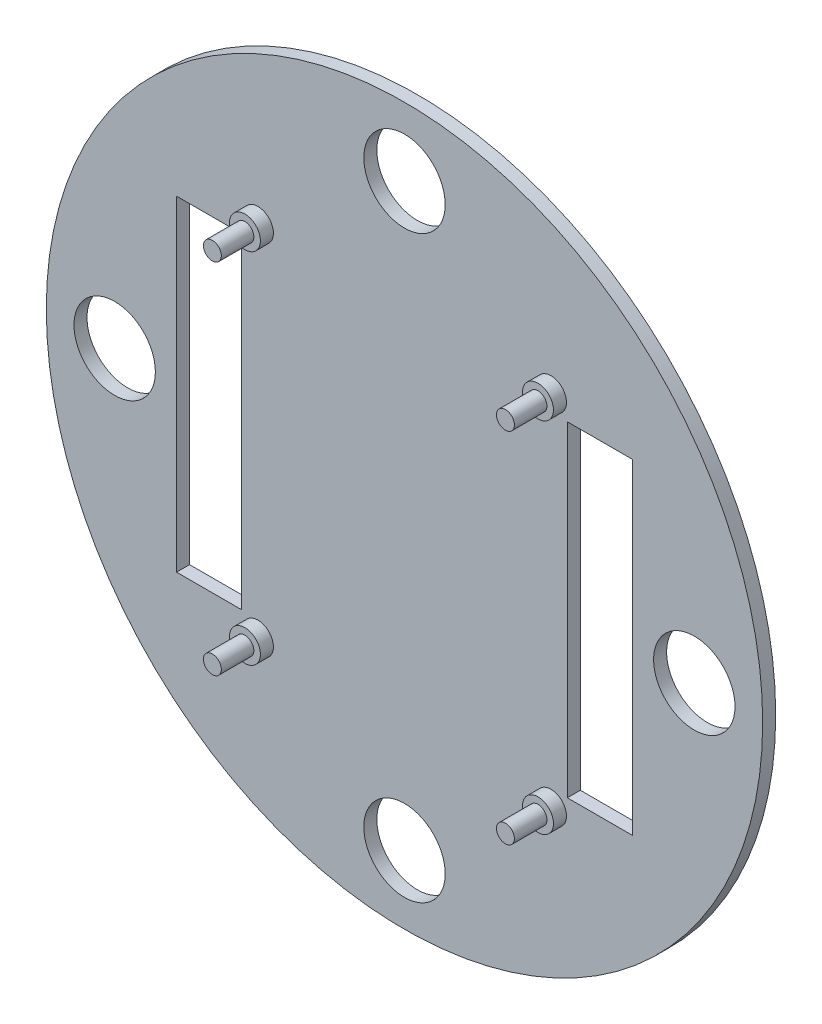
from build123d import *

# Parameters (mm, degrees)
SKETCH4_R           = 59
BOSS_EXTRUDE3_DEPTH = 2
SKETCH5_R           = 1.375
BOSS_EXTRUDE5_DEPTH = 7
SKETCH8_R           = 2.375
BOSS_EXTRUDE6_DEPTH = 2
BOSS_EXTRUDE7_DEPTH = 18
SKETCH10_R          = 7.5
CUT_EXTRUDE1_DEPTH  = 18
SKETCH12_R          = 57.5
CUT_EXTRUDE2_DEPTH  = 5
CUT_EXTRUDE3_DEPTH  = 5.5
SKETCH15_R          = 89.714021058
SKETCH15_R_2        = 57
CUT_EXTRUDE4_DEPTH  = 22
SKETCH16_R          = 62.462022857
CUT_EXTRUDE8_DEPTH  = 52
CUT_EXTRUDE9_DEPTH  = 52
SKETCH18_R          = 80.62246508
SKETCH18_R_2        = 55
CUT_EXTRUDE10_DEPTH = 10
SKETCH19_R          = 55
BOSS_EXTRUDE8_DEPTH = 2
SKETCH20_R          = 6.25
CUT_EXTRUDE11_DEPTH = 2
SKETCH21_W          = 10
SKETCH21_H          = 50
CUT_EXTRUDE12_DEPTH = 3


with BuildPart() as part:
    # Sketch4 → Boss-Extrude3 (new body)
    with BuildSketch(Plane.XY):
        Circle(SKETCH4_R)
    extrude(amount=BOSS_EXTRUDE3_DEPTH)

    # Sketch5 → Boss-Extrude5 (add)
    with BuildSketch(Plane.XY.offset(2)):
        with Locations((-22.5, 27.5)):
            Circle(SKETCH5_R)
        with Locations((22.5, 27.5)):
            Circle(SKETCH5_R)
        with Locations((22.5, -27.5)):
            Circle(SKETCH5_R)
        with Locations((-22.5, -27.5)):
            Circle(SKETCH5_R)
    extrude(amount=BOSS_EXTRUDE5_DEPTH)

    # Sketch8 → Boss-Extrude6 (add)
    with BuildSketch(Plane.XY.offset(2)):
        with Locations((-22.5, 27.5)):
            Circle(SKETCH8_R)
        with Locations((22.5, 27.5)):
            Circle(SKETCH8_R)
        with Locations((-22.5, -27.5)):
            Circle(SKETCH8_R)
        with Locations((22.5, -27.5)):
            Circle(SKETCH8_R)
    extrude(amount=BOSS_EXTRUDE6_DEPTH)

    # Sketch9 → Boss-Extrude7 (add)
    with BuildSketch(Plane.XY.offset(2)):
        with BuildLine():
            ThreePointArc((-4.745762712, 55.798546005), (0, 56), (4.745762712, 55.798546005))
            Line((4.745762712, 55.798546005), (5, 58.787753827))
            ThreePointArc((5, 58.787753827), (0, 59), (-5, 58.787753827))
            Line((-5, 58.787753827), (-4.745762712, 55.798546005))
        make_face()
        with BuildLine():
            Line((-55.798546005, 4.745762712), (-58.787753827, 5))
            ThreePointArc((-58.787753827, 5), (-59, 0), (-58.787753827, -5))
            Line((-58.787753827, -5), (-55.798546005, -4.745762712))
            ThreePointArc((-55.798546005, -4.745762712), (-56, 0), (-55.798546005, 4.745762712))
        make_face()
        with BuildLine():
            ThreePointArc((58.787753827, -5), (59, 0), (58.787753827, 5))
            Line((58.787753827, 5), (55.798546005, 4.745762712))
            ThreePointArc((55.798546005, 4.745762712), (56, 0), (55.798546005, -4.745762712))
            Line((55.798546005, -4.745762712), (58.787753827, -5))
        make_face()
        with BuildLine():
            ThreePointArc((-4.745762712, -55.798546005), (0, -56), (4.745762712, -55.798546005))
            Line((4.745762712, -55.798546005), (5, -58.787753827))
            ThreePointArc((5, -58.787753827), (0, -59), (-5, -58.787753827))
            Line((-5, -58.787753827), (-4.745762712, -55.798546005))
        make_face()
    extrude(amount=BOSS_EXTRUDE7_DEPTH)

    # Sketch10 → Cut-Extrude1 (cut)
    with BuildSketch(Plane.XY.offset(2)):
        with Locations((-40, 0)):
            Circle(SKETCH10_R)
    extrude(amount=-CUT_EXTRUDE1_DEPTH, mode=Mode.SUBTRACT)

    # Sketch12 → Cut-Extrude2 (cut)
    with BuildSketch(Plane.XY.offset(20)):
        Circle(SKETCH12_R)
    extrude(amount=-CUT_EXTRUDE2_DEPTH, mode=Mode.SUBTRACT)

    # Sketch13 → Cut-Extrude3 (cut)
    with BuildSketch(Plane(origin=(0, 0, 0), x_dir=(-1, 0, 0), z_dir=(0, 0, -1))):
        with BuildLine():
            Line((-57.243329786, 4.868644068), (-58.787753827, 5))
            ThreePointArc((-58.787753827, 5), (-59, 0), (-58.787753827, -5))
            Line((-58.787753827, -5), (-57.243329786, -4.868644068))
            ThreePointArc((-57.243329786, -4.868644068), (-57.45, 0), (-57.243329786, 4.868644068))
        make_face()
        with BuildLine():
            ThreePointArc((5, 58.787753827), (0, 59), (-5, 58.787753827))
            Line((-5, 58.787753827), (-4.868644068, 57.243329786))
            ThreePointArc((-4.868644068, 57.243329786), (0, 57.45), (4.868644068, 57.243329786))
            Line((4.868644068, 57.243329786), (5, 58.787753827))
        make_face()
        with BuildLine():
            Line((-4.868644068, -57.243329786), (-5, -58.787753827))
            ThreePointArc((-5, -58.787753827), (0, -59), (5, -58.787753827))
            Line((5, -58.787753827), (4.868644068, -57.243329786))
            ThreePointArc((4.868644068, -57.243329786), (0, -57.45), (-4.868644068, -57.243329786))
        make_face()
        with BuildLine():
            ThreePointArc((58.787753827, -5), (59, 0), (58.787753827, 5))
            Line((58.787753827, 5), (57.243329786, 4.868644068))
            ThreePointArc((57.243329786, 4.868644068), (57.45, 0), (57.243329786, -4.868644068))
            Line((57.243329786, -4.868644068), (58.787753827, -5))
        make_face()
    extrude(amount=-CUT_EXTRUDE3_DEPTH, mode=Mode.SUBTRACT)

    # Sketch15 → Cut-Extrude4 (cut)
    with BuildSketch(Plane(origin=(0, 0, 0), x_dir=(-1, 0, 0), z_dir=(0, 0, -1))):
        Circle(SKETCH15_R)
        Circle(SKETCH15_R_2, mode=Mode.SUBTRACT)
    extrude(amount=-CUT_EXTRUDE4_DEPTH, mode=Mode.SUBTRACT)

    # Sketch16 → Cut-Extrude8 (cut)
    with BuildSketch(Plane.XY.offset(2)):
        Circle(SKETCH16_R)
        with BuildLine():
            Line((55.798546005, 4.745762712), (56.794948612, 4.830508475))
            ThreePointArc((56.794948612, 4.830508475), (40.305086528, 40.305086528), (4.830508475, 56.794948612))
            Line((4.830508475, 56.794948612), (4.745762712, 55.798546005))
            ThreePointArc((4.745762712, 55.798546005), (0, 56), (-4.745762712, 55.798546005))
            Line((-4.745762712, 55.798546005), (-4.830508475, 56.794948612))
            ThreePointArc((-4.830508475, 56.794948612), (-40.305086528, 40.305086528), (-56.794948612, 4.830508475))
            Line((-56.794948612, 4.830508475), (-55.798546005, 4.745762712))
            ThreePointArc((-55.798546005, 4.745762712), (-56, 0), (-55.798546005, -4.745762712))
            Line((-55.798546005, -4.745762712), (-56.794948612, -4.830508475))
            ThreePointArc((-56.794948612, -4.830508475), (-40.305086528, -40.305086528), (-4.830508475, -56.794948612))
            Line((-4.830508475, -56.794948612), (-4.745762712, -55.798546005))
            ThreePointArc((-4.745762712, -55.798546005), (0, -56), (4.745762712, -55.798546005))
            Line((4.745762712, -55.798546005), (4.830508475, -56.794948612))
            ThreePointArc((4.830508475, -56.794948612), (40.305086528, -40.305086528), (56.794948612, -4.830508475))
            Line((56.794948612, -4.830508475), (55.798546005, -4.745762712))
            ThreePointArc((55.798546005, -4.745762712), (56, 0), (55.798546005, 4.745762712))
        make_face(mode=Mode.SUBTRACT)
    extrude(amount=CUT_EXTRUDE8_DEPTH, mode=Mode.SUBTRACT)

    # Sketch17 → Cut-Extrude9 (cut)
    with BuildSketch(Plane.XY.offset(2)):
        with BuildLine():
            Line((-5, 57), (5, 57))
            Line((5, 57), (4.806106124, 54.789609817))
            ThreePointArc((4.806106124, 54.789609817), (0, 55), (-4.806106124, 54.789609817))
            Line((-4.806106124, 54.789609817), (-5, 57))
        make_face()
        with BuildLine():
            Line((54.789609817, 4.806106124), (57, 5))
            Line((57, 5), (57, -5))
            Line((57, -5), (54.789609817, -4.806106124))
            ThreePointArc((54.789609817, -4.806106124), (55, 0), (54.789609817, 4.806106124))
        make_face()
        with BuildLine():
            Line((4.806106124, -54.789609817), (5, -57))
            Line((5, -57), (-5, -57))
            Line((-5, -57), (-4.806106124, -54.789609817))
            ThreePointArc((-4.806106124, -54.789609817), (0, -55), (4.806106124, -54.789609817))
        make_face()
        with BuildLine():
            Line((-54.789609817, -4.806106124), (-57, -5))
            Line((-57, -5), (-57, 5))
            Line((-57, 5), (-54.789609817, 4.806106124))
            ThreePointArc((-54.789609817, 4.806106124), (-55, 0), (-54.789609817, -4.806106124))
        make_face()
    extrude(amount=-CUT_EXTRUDE9_DEPTH, mode=Mode.SUBTRACT)

    # Sketch18 → Cut-Extrude10 (cut)
    with BuildSketch(Plane.XY.offset(2)):
        Circle(SKETCH18_R)
        Circle(SKETCH18_R_2, mode=Mode.SUBTRACT)
    extrude(amount=-CUT_EXTRUDE10_DEPTH, mode=Mode.SUBTRACT)

    # Sketch19 → Boss-Extrude8 (add)
    with BuildSketch(Plane.XY.offset(2)):
        Circle(SKETCH19_R)
    extrude(amount=-BOSS_EXTRUDE8_DEPTH)

    # Sketch20 → Cut-Extrude11 (cut)
    with BuildSketch(Plane.XY.offset(2)):
        with Locations((0, 44.5)):
            Circle(SKETCH20_R)
        with Locations((44.5, 0)):
            Circle(SKETCH20_R)
        with Locations((0, -44.5)):
            Circle(SKETCH20_R)
        with Locations((-44.5, 0)):
            Circle(SKETCH20_R)
    extrude(amount=-CUT_EXTRUDE11_DEPTH, mode=Mode.SUBTRACT)

    # Sketch21 → Cut-Extrude12 (cut)
    with BuildSketch(Plane.XY.offset(2)):
        with Locations((30, 0)):
            Rectangle(SKETCH21_W, SKETCH21_H)
        with Locations((-30, 0)):
            Rectangle(SKETCH21_W, SKETCH21_H)
    extrude(amount=-CUT_EXTRUDE12_DEPTH, mode=Mode.SUBTRACT)


solid = part.part
